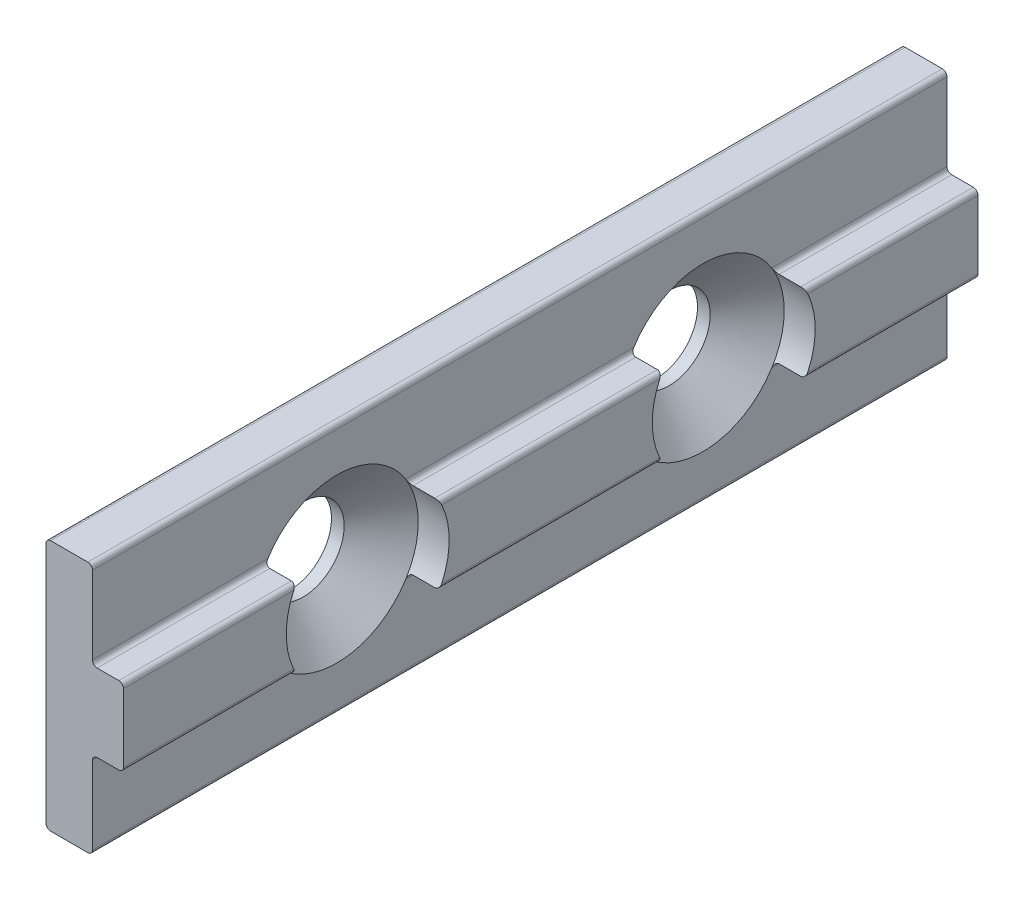
from build123d import *

# Parameters (mm, degrees)
BOSS_EXTRUDE1_DEPTH                         = 70.04
CSK_FOR_1_4_FLAT_HEAD_MACHINE_SCREW_2_COUNT = 2
CSK_FOR_1_4_FLAT_HEAD_MACHINE_SCREW_2_PITCH = 30
CUT_EXTRUDE2_REACH                          = 4.54
SKETCH8_R                                   = 6.6772536


with BuildPart() as part:
    # Sketch1 → Boss-Extrude1 (new body)
    with BuildSketch(Plane.XY.offset(12.7)):
        with BuildLine():
            Line((-3.81, 9.9314), (-3.81, -9.9314))
            ThreePointArc((-3.81, -9.9314), (-3.698407684, -10.200807684), (-3.429, -10.3124))
            Line((-3.429, -10.3124), (-0.381, -10.3124))
            ThreePointArc((-0.381, -10.3124), (-0.111592316, -10.200807684), (0, -9.9314))
            Line((0, -9.9314), (0, -3.556))
            ThreePointArc((0, -3.556), (0.111592316, -3.286592316), (0.381, -3.175))
            Line((0.381, -3.175), (2.159, -3.175))
            ThreePointArc((2.159, -3.175), (2.428407684, -3.063407684), (2.54, -2.794))
            Line((2.54, -2.794), (2.54, 2.794))
            ThreePointArc((2.54, 2.794), (2.428407684, 3.063407684), (2.159, 3.175))
            Line((2.159, 3.175), (0.381, 3.175))
            ThreePointArc((0.381, 3.175), (0.111592316, 3.286592316), (0, 3.556))
            Line((0, 3.556), (0, 9.9314))
            ThreePointArc((0, 9.9314), (-0.111592316, 10.200807684), (-0.381, 10.3124))
            Line((-0.381, 10.3124), (-3.429, 10.3124))
            ThreePointArc((-3.429, 10.3124), (-3.698407684, 10.200807684), (-3.81, 9.9314))
        make_face()
    extrude(amount=-BOSS_EXTRUDE1_DEPTH)

    # Sketch7 → CSK for 1/4 Flat Head Machine Screw (100)1 (revolve, cut)
    with BuildSketch(Plane(origin=(0, 0, -37.32), x_dir=(0, 0, -1), z_dir=(0, 1, 0))):
        Polygon((0, 0), (0, 3.81), (3.3782, 3.81), (3.3782, 2.768234659), (6.6772536, 0), align=None)
    csk_for_1_4_flat_head_machine_screw_100 = revolve(axis=Axis((6.35, 0, -37.32), (-1, 0, 0)), mode=Mode.SUBTRACT)

    # CSK for 1_4 Flat Head Machine Screw  2: CSK for 1/4 Flat Head Machine Screw (100)1 ×2
    with Locations(*[(0, 0, i * CSK_FOR_1_4_FLAT_HEAD_MACHINE_SCREW_2_PITCH) for i in range(1, CSK_FOR_1_4_FLAT_HEAD_MACHINE_SCREW_2_COUNT)]):
        add(csk_for_1_4_flat_head_machine_screw_100, mode=Mode.SUBTRACT)

    # Sketch8 → Cut-Extrude2 (cut, up to next)
    with BuildSketch(Plane(origin=(0, 0, 0), x_dir=(0, 0, -1), z_dir=(1, 0, 0)), mode=Mode.PRIVATE) as cut_extrude2_sk1:
        with Locations((7.32, 0)):
            Circle(SKETCH8_R)
    cut_extrude2_tool1 = extrude(cut_extrude2_sk1.sketch, amount=CUT_EXTRUDE2_REACH, mode=Mode.PRIVATE) & part.part
    add(cut_extrude2_tool1.solids().sort_by_distance((0, 0, -7.32))[0], mode=Mode.SUBTRACT)
    # Sketch8 → Cut-Extrude2 (cut, up to next)
    with BuildSketch(Plane(origin=(0, 0, 0), x_dir=(0, 0, -1), z_dir=(1, 0, 0)), mode=Mode.PRIVATE) as cut_extrude2_sk2:
        with Locations((37.32, 0)):
            Circle(SKETCH8_R)
    cut_extrude2_tool2 = extrude(cut_extrude2_sk2.sketch, amount=CUT_EXTRUDE2_REACH, mode=Mode.PRIVATE) & part.part
    add(cut_extrude2_tool2.solids().sort_by_distance((0, 0, -37.32))[0], mode=Mode.SUBTRACT)


solid = part.part
